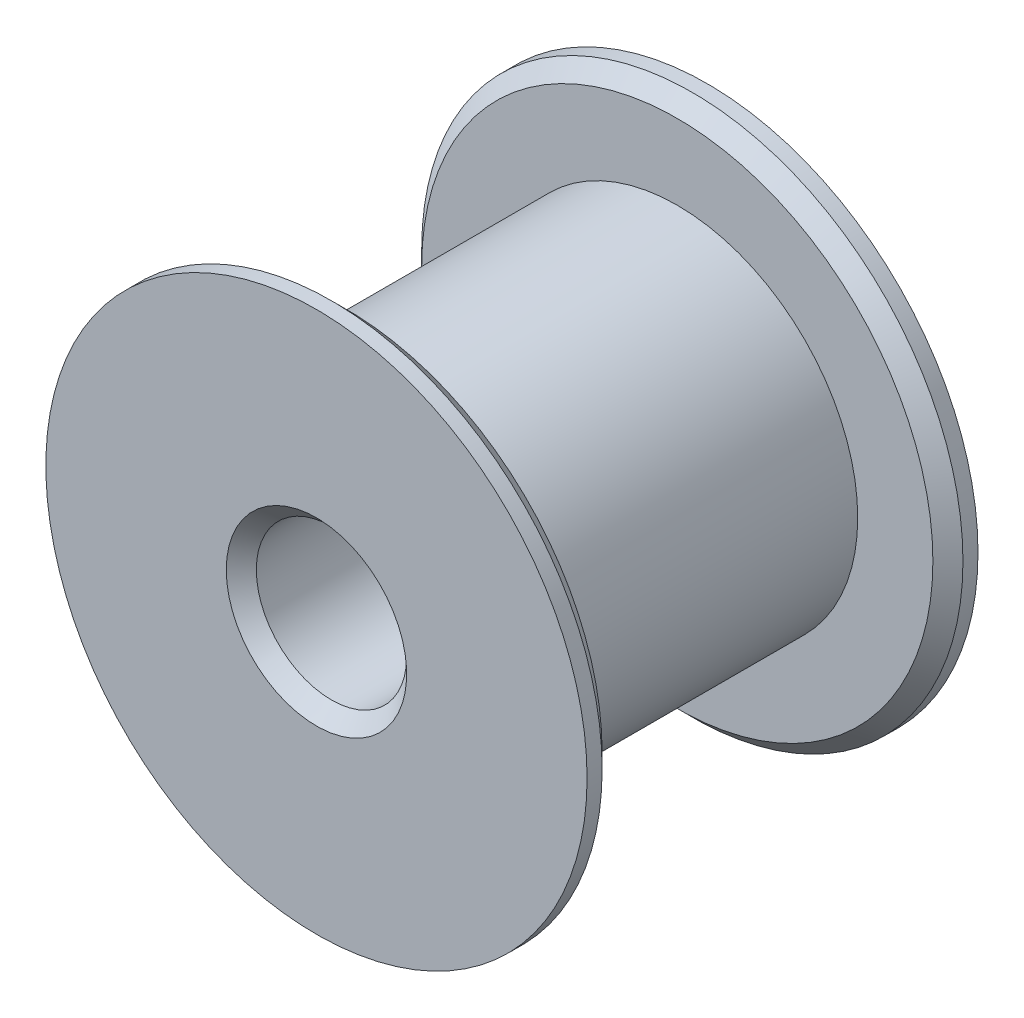
from build123d import *

# Parameters (mm, degrees)
CHAMFER1_SIZE = 0.5


with BuildPart() as part:
    # Sketch1 → Revolve1 (revolve)
    with BuildSketch(Plane(origin=(0, 0, 0), x_dir=(1, 0, 0), z_dir=(0, 1, 0))):
        Polygon((-2.5, 0), (-2.5, 13), (-9, 13), (-9, 12), (-6, 12), (-6, 1), (-9, 1), (-9, 0), align=None)
    revolve(axis=Axis((0, 0, 0), (0, 0, -1)))

    # Chamfer1
    chamfer1_edges = [part.edges().sort_by_distance(p)[0] for p in [
        (2.5, 0, -13),
        (2.5, 0, 0),
        (9, 0, -1),
        (9, 0, -12),
    ]]
    chamfer(chamfer1_edges, length=CHAMFER1_SIZE)


solid = part.part
